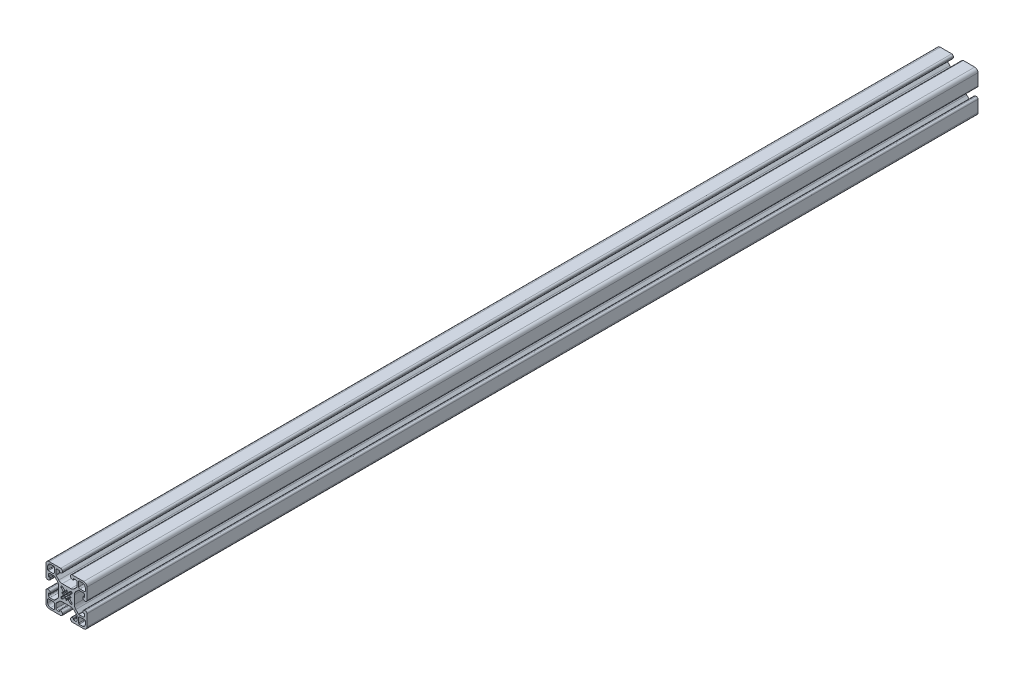
from build123d import *

# Parameters (mm, degrees)
EXTRUDE1_DEPTH = 870


with BuildPart() as part:
    # Sketch1 → Extrude1 (new body)
    with BuildSketch(Plane.XY):
        with BuildLine():
            Line((-5.63, 20), (-16.83, 20))
            ThreePointArc((-16.83, 20), (-19.071528496, 19.071528497), (-20, 16.83))
            Line((-20, 16.83), (-20, 5.63))
            ThreePointArc((-20, 5.63), (-19.540157646, 4.519842354), (-18.43, 4.06))
            Line((-18.43, 4.06), (-17.57, 4.06))
            ThreePointArc((-17.57, 4.06), (-16.459842353, 4.519842354), (-16, 5.63))
            Line((-16, 5.63), (-16, 6.605))
            ThreePointArc((-16, 6.605), (-16.073223305, 6.781776695), (-16.25, 6.855))
            Line((-16.25, 6.855), (-17.25, 6.855))
            ThreePointArc((-17.25, 6.855), (-17.426776695, 6.928223305), (-17.5, 7.105))
            Line((-17.5, 7.105), (-17.5, 9.015))
            ThreePointArc((-17.5, 9.015), (-17.128025612, 9.913025612), (-16.23, 10.285))
            Line((-16.23, 10.285), (-12.216214636, 10.285))
            ThreePointArc((-12.216214636, 10.285), (-11.875626381, 10.217252784), (-11.5868896, 10.024325035))
            Line((-11.5868896, 10.024325035), (-9.076242789, 7.513678224))
            ThreePointArc((-9.076242789, 7.513678224), (-8.046572221, 5.972667318), (-7.685, 4.154921014))
            Line((-7.685, 4.154921014), (-7.685, -4.154921014))
            ThreePointArc((-7.685, -4.154921014), (-8.046572221, -5.972667317), (-9.076242789, -7.513678224))
            Line((-9.076242789, -7.513678224), (-11.5868896, -10.024325035))
            ThreePointArc((-11.5868896, -10.024325035), (-11.875626381, -10.217252784), (-12.216214636, -10.285))
            Line((-12.216214636, -10.285), (-16.23, -10.285))
            ThreePointArc((-16.23, -10.285), (-17.128025612, -9.913025612), (-17.5, -9.015))
            Line((-17.5, -9.015), (-17.5, -7.105))
            ThreePointArc((-17.5, -7.105), (-17.426776695, -6.928223305), (-17.25, -6.855))
            Line((-17.25, -6.855), (-16.25, -6.855))
            ThreePointArc((-16.25, -6.855), (-16.073223305, -6.781776695), (-16, -6.605))
            Line((-16, -6.605), (-16, -5.63))
            ThreePointArc((-16, -5.63), (-16.459842354, -4.519842353), (-17.57, -4.06))
            Line((-17.57, -4.06), (-18.43, -4.06))
            ThreePointArc((-18.43, -4.06), (-19.540157646, -4.519842353), (-20, -5.63))
            Line((-20, -5.63), (-20, -16.83))
            ThreePointArc((-20, -16.83), (-19.071528496, -19.071528496), (-16.83, -20))
            Line((-16.83, -20), (-5.63, -20))
            ThreePointArc((-5.63, -20), (-4.519842354, -19.540157646), (-4.06, -18.43))
            Line((-4.06, -18.43), (-4.06, -17.57))
            ThreePointArc((-4.06, -17.57), (-4.519842354, -16.459842353), (-5.63, -16))
            Line((-5.63, -16), (-6.605, -16))
            ThreePointArc((-6.605, -16), (-6.781776695, -16.073223305), (-6.855, -16.25))
            Line((-6.855, -16.25), (-6.855, -17.25))
            ThreePointArc((-6.855, -17.25), (-6.928223305, -17.426776695), (-7.105, -17.5))
            Line((-7.105, -17.5), (-9.015, -17.5))
            ThreePointArc((-9.015, -17.5), (-9.913025612, -17.128025612), (-10.285, -16.23))
            Line((-10.285, -16.23), (-10.285, -12.216214635))
            ThreePointArc((-10.285, -12.216214635), (-10.217252784, -11.875626381), (-10.024325035, -11.5868896))
            Line((-10.024325035, -11.5868896), (-7.513678224, -9.076242789))
            ThreePointArc((-7.513678224, -9.076242789), (-5.972667317, -8.04657222), (-4.154921014, -7.685))
            Line((-4.154921014, -7.685), (4.154921014, -7.685))
            ThreePointArc((4.154921014, -7.685), (5.972667317, -8.04657222), (7.513678224, -9.076242789))
            Line((7.513678224, -9.076242789), (10.024325035, -11.5868896))
            ThreePointArc((10.024325035, -11.5868896), (10.217252784, -11.875626381), (10.285, -12.216214636))
            Line((10.285, -12.216214636), (10.285, -16.23))
            ThreePointArc((10.285, -16.23), (9.913025612, -17.128025612), (9.015, -17.5))
            Line((9.015, -17.5), (7.105, -17.5))
            ThreePointArc((7.105, -17.5), (6.928223305, -17.426776695), (6.855, -17.25))
            Line((6.855, -17.25), (6.855, -16.25))
            ThreePointArc((6.855, -16.25), (6.781776695, -16.073223305), (6.605, -16))
            Line((6.605, -16), (5.63, -16))
            ThreePointArc((5.63, -16), (4.519842354, -16.459842353), (4.06, -17.57))
            Line((4.06, -17.57), (4.06, -18.43))
            ThreePointArc((4.06, -18.43), (4.519842354, -19.540157646), (5.63, -20))
            Line((5.63, -20), (16.83, -20))
            ThreePointArc((16.83, -20), (19.071528496, -19.071528496), (20, -16.83))
            Line((20, -16.83), (20, -5.63))
            ThreePointArc((20, -5.63), (19.540157646, -4.519842353), (18.43, -4.06))
            Line((18.43, -4.06), (17.57, -4.06))
            ThreePointArc((17.57, -4.06), (16.459842354, -4.519842353), (16, -5.63))
            Line((16, -5.63), (16, -6.605))
            ThreePointArc((16, -6.605), (16.073223305, -6.781776695), (16.25, -6.855))
            Line((16.25, -6.855), (17.25, -6.855))
            ThreePointArc((17.25, -6.855), (17.426776695, -6.928223305), (17.5, -7.105))
            Line((17.5, -7.105), (17.5, -9.015))
            ThreePointArc((17.5, -9.015), (17.128025612, -9.913025612), (16.23, -10.285))
            Line((16.23, -10.285), (12.216214636, -10.285))
            ThreePointArc((12.216214636, -10.285), (11.875626381, -10.217252784), (11.5868896, -10.024325035))
            Line((11.5868896, -10.024325035), (9.076242789, -7.513678224))
            ThreePointArc((9.076242789, -7.513678224), (8.046572221, -5.972667317), (7.685, -4.154921014))
            Line((7.685, -4.154921014), (7.685, 4.154921014))
            ThreePointArc((7.685, 4.154921014), (8.046572221, 5.972667318), (9.076242789, 7.513678224))
            Line((9.076242789, 7.513678224), (11.5868896, 10.024325035))
            ThreePointArc((11.5868896, 10.024325035), (11.875626381, 10.217252784), (12.216214636, 10.285))
            Line((12.216214636, 10.285), (16.23, 10.285))
            ThreePointArc((16.23, 10.285), (17.128025612, 9.913025612), (17.5, 9.015))
            Line((17.5, 9.015), (17.5, 7.105))
            ThreePointArc((17.5, 7.105), (17.426776695, 6.928223305), (17.25, 6.855))
            Line((17.25, 6.855), (16.25, 6.855))
            ThreePointArc((16.25, 6.855), (16.073223305, 6.781776695), (16, 6.605))
            Line((16, 6.605), (16, 5.63))
            ThreePointArc((16, 5.63), (16.459842354, 4.519842354), (17.57, 4.06))
            Line((17.57, 4.06), (18.43, 4.06))
            ThreePointArc((18.43, 4.06), (19.540157646, 4.519842354), (20, 5.63))
            Line((20, 5.63), (20, 16.83))
            ThreePointArc((20, 16.83), (19.071528496, 19.071528496), (16.83, 20))
            Line((16.83, 20), (5.63, 20))
            ThreePointArc((5.63, 20), (4.519842354, 19.540157647), (4.06, 18.43))
            Line((4.06, 18.43), (4.06, 17.57))
            ThreePointArc((4.06, 17.57), (4.519842354, 16.459842354), (5.63, 16))
            Line((5.63, 16), (6.605, 16))
            ThreePointArc((6.605, 16), (6.781776695, 16.073223305), (6.855, 16.25))
            Line((6.855, 16.25), (6.855, 17.25))
            ThreePointArc((6.855, 17.25), (6.928223305, 17.426776695), (7.105, 17.5))
            Line((7.105, 17.5), (9.015, 17.5))
            ThreePointArc((9.015, 17.5), (9.913025612, 17.128025612), (10.285, 16.23))
            Line((10.285, 16.23), (10.285, 12.216214636))
            ThreePointArc((10.285, 12.216214636), (10.217252784, 11.875626381), (10.024325035, 11.5868896))
            Line((10.024325035, 11.5868896), (7.513678224, 9.07624279))
            ThreePointArc((7.513678224, 9.07624279), (5.972667317, 8.046572221), (4.154921014, 7.685))
            Line((4.154921014, 7.685), (-4.154921014, 7.685))
            ThreePointArc((-4.154921014, 7.685), (-5.972667317, 8.046572221), (-7.513678224, 9.07624279))
            Line((-7.513678224, 9.07624279), (-10.024325035, 11.5868896))
            ThreePointArc((-10.024325035, 11.5868896), (-10.217252784, 11.875626381), (-10.285, 12.216214636))
            Line((-10.285, 12.216214636), (-10.285, 16.23))
            ThreePointArc((-10.285, 16.23), (-9.913025612, 17.128025612), (-9.015, 17.5))
            Line((-9.015, 17.5), (-7.105, 17.5))
            ThreePointArc((-7.105, 17.5), (-6.928223305, 17.426776695), (-6.855, 17.25))
            Line((-6.855, 17.25), (-6.855, 16.25))
            ThreePointArc((-6.855, 16.25), (-6.781776695, 16.073223305), (-6.605, 16))
            Line((-6.605, 16), (-5.63, 16))
            ThreePointArc((-5.63, 16), (-4.519842354, 16.459842354), (-4.06, 17.57))
            Line((-4.06, 17.57), (-4.06, 18.43))
            ThreePointArc((-4.06, 18.43), (-4.519842354, 19.540157647), (-5.63, 20))
        make_face()
        with BuildLine():
            Line((12.4898, -18.345), (15.545, -18.345))
            ThreePointArc((15.545, -18.345), (17.524898987, -17.524898987), (18.345, -15.545))
            Line((18.345, -15.545), (18.345, -12.4898))
            ThreePointArc((18.345, -12.4898), (18.160477272, -12.044322728), (17.715, -11.8598))
            Line((17.715, -11.8598), (13.1298, -11.8598))
            ThreePointArc((13.1298, -11.8598), (12.231774388, -12.231774388), (11.8598, -13.1298))
            Line((11.8598, -13.1298), (11.8598, -17.715))
            ThreePointArc((11.8598, -17.715), (12.044322728, -18.160477272), (12.4898, -18.345))
        make_face(mode=Mode.SUBTRACT)
        with BuildLine():
            Line((-18.345, -12.4898), (-18.345, -15.545))
            ThreePointArc((-18.345, -15.545), (-17.524898987, -17.524898987), (-15.545, -18.345))
            Line((-15.545, -18.345), (-12.4898, -18.345))
            ThreePointArc((-12.4898, -18.345), (-12.044322728, -18.160477272), (-11.8598, -17.715))
            Line((-11.8598, -17.715), (-11.8598, -13.1298))
            ThreePointArc((-11.8598, -13.1298), (-12.231774388, -12.231774388), (-13.1298, -11.8598))
            Line((-13.1298, -11.8598), (-17.715, -11.8598))
            ThreePointArc((-17.715, -11.8598), (-18.160477272, -12.044322728), (-18.345, -12.4898))
        make_face(mode=Mode.SUBTRACT)
        with BuildLine():
            Line((18.345, 12.4898), (18.345, 15.545))
            ThreePointArc((18.345, 15.545), (17.524898987, 17.524898987), (15.545, 18.345))
            Line((15.545, 18.345), (12.4898, 18.345))
            ThreePointArc((12.4898, 18.345), (12.044322728, 18.160477272), (11.8598, 17.715))
            Line((11.8598, 17.715), (11.8598, 13.1298))
            ThreePointArc((11.8598, 13.1298), (12.231774388, 12.231774388), (13.1298, 11.8598))
            Line((13.1298, 11.8598), (17.715, 11.8598))
            ThreePointArc((17.715, 11.8598), (18.160477272, 12.044322728), (18.345, 12.4898))
        make_face(mode=Mode.SUBTRACT)
        with BuildLine():
            Line((-12.4898, 18.345), (-15.545, 18.345))
            ThreePointArc((-15.545, 18.345), (-17.524898987, 17.524898987), (-18.345, 15.545))
            Line((-18.345, 15.545), (-18.345, 12.4898))
            ThreePointArc((-18.345, 12.4898), (-18.160477272, 12.044322728), (-17.715, 11.8598))
            Line((-17.715, 11.8598), (-13.1298, 11.8598))
            ThreePointArc((-13.1298, 11.8598), (-12.231774388, 12.231774388), (-11.8598, 13.1298))
            Line((-11.8598, 13.1298), (-11.8598, 17.715))
            ThreePointArc((-11.8598, 17.715), (-12.044322728, 18.160477272), (-12.4898, 18.345))
        make_face(mode=Mode.SUBTRACT)
        with BuildLine():
            Line((-4.84811685, -5.43930974), (-3.712038621, -5.126252183))
            Line((-3.712038621, -5.126252183), (-1.590718277, -3.00493184))
            ThreePointArc((-1.590718277, -3.00493184), (-1.120609643, -3.210020877), (-0.625, -3.342061489))
            Line((-0.625, -3.342061489), (-0.492259234, -4.087640441))
            ThreePointArc((-0.492259234, -4.087640441), (0, -4.5), (0.492259234, -4.087640441))
            Line((0.492259234, -4.087640441), (0.625, -3.342061489))
            ThreePointArc((0.625, -3.342061489), (1.120609643, -3.210020877), (1.590718277, -3.00493184))
            Line((1.590718277, -3.00493184), (3.712038621, -5.126252183))
            Line((3.712038621, -5.126252183), (4.84811685, -5.43930974))
            ThreePointArc((4.84811685, -5.43930974), (5.303300859, -5.303300859), (5.43930974, -4.84811685))
            Line((5.43930974, -4.84811685), (5.126252183, -3.712038621))
            Line((5.126252183, -3.712038621), (3.00493184, -1.590718277))
            ThreePointArc((3.00493184, -1.590718277), (3.210020877, -1.120609643), (3.342061489, -0.625))
            Line((3.342061489, -0.625), (4.087640441, -0.492259234))
            ThreePointArc((4.087640441, -0.492259234), (4.5, 0), (4.087640441, 0.492259234))
            Line((4.087640441, 0.492259234), (3.342061489, 0.625))
            ThreePointArc((3.342061489, 0.625), (3.210020877, 1.120609643), (3.00493184, 1.590718277))
            Line((3.00493184, 1.590718277), (5.126252183, 3.712038621))
            Line((5.126252183, 3.712038621), (5.43930974, 4.84811685))
            ThreePointArc((5.43930974, 4.84811685), (5.303300859, 5.303300859), (4.84811685, 5.43930974))
            Line((4.84811685, 5.43930974), (3.712038621, 5.126252183))
            Line((3.712038621, 5.126252183), (1.590718277, 3.00493184))
            ThreePointArc((1.590718277, 3.00493184), (1.120609643, 3.210020877), (0.625, 3.342061489))
            Line((0.625, 3.342061489), (0.492259234, 4.087640441))
            ThreePointArc((0.492259234, 4.087640441), (0, 4.5), (-0.492259234, 4.087640441))
            Line((-0.492259234, 4.087640441), (-0.625, 3.342061489))
            ThreePointArc((-0.625, 3.342061489), (-1.120609643, 3.210020877), (-1.590718277, 3.00493184))
            Line((-1.590718277, 3.00493184), (-3.712038621, 5.126252183))
            Line((-3.712038621, 5.126252183), (-4.84811685, 5.43930974))
            ThreePointArc((-4.84811685, 5.43930974), (-5.303300859, 5.303300859), (-5.43930974, 4.84811685))
            Line((-5.43930974, 4.84811685), (-5.126252183, 3.712038621))
            Line((-5.126252183, 3.712038621), (-3.00493184, 1.590718277))
            ThreePointArc((-3.00493184, 1.590718277), (-3.210020877, 1.120609643), (-3.342061489, 0.625))
            Line((-3.342061489, 0.625), (-4.087640441, 0.492259234))
            ThreePointArc((-4.087640441, 0.492259234), (-4.5, 0), (-4.087640441, -0.492259234))
            Line((-4.087640441, -0.492259234), (-3.342061489, -0.625))
            ThreePointArc((-3.342061489, -0.625), (-3.210020877, -1.120609643), (-3.00493184, -1.590718277))
            Line((-3.00493184, -1.590718277), (-5.126252183, -3.712038621))
            Line((-5.126252183, -3.712038621), (-5.43930974, -4.84811685))
            ThreePointArc((-5.43930974, -4.84811685), (-5.303300859, -5.303300859), (-4.84811685, -5.43930974))
        make_face(mode=Mode.SUBTRACT)
    extrude(amount=-EXTRUDE1_DEPTH)


solid = part.part
